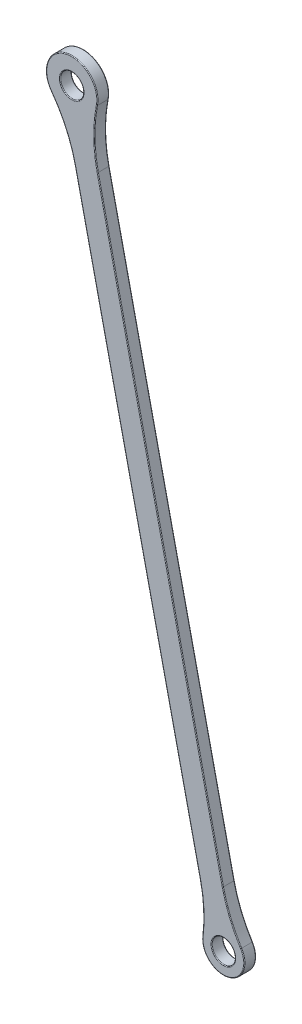
from build123d import *

# Parameters (mm, degrees)
BOSS_EXTRUDE1_DEPTH = 2.5
FILLET1_R           = 30
FILLET2_R           = 0.15


with BuildPart() as part:
    # Sketch1 → Boss-Extrude1 (new body)
    with BuildSketch(Plane.XY):
        with BuildLine():
            Line((12.060958277, 80.951296551), (-20.422285901, 225.342566543))
            ThreePointArc((-20.422285901, 225.342566543), (-17.434540729, 223.452228269), (-15.544202455, 226.439973441))
            Line((-15.544202455, 226.439973441), (16.939041723, 82.048703449))
            ThreePointArc((16.939041723, 82.048703449), (13.951296551, 83.939041723), (12.060958277, 80.951296551))
        make_face()
        with BuildLine():
            ThreePointArc((-14.468967679, 221.660447295), (-19.190391766, 231.257161782), (-19.347051125, 220.563040398))
            Line((-19.347051125, 220.563040398), (-20.422285901, 225.342566543))
            ThreePointArc((-20.422285901, 225.342566543), (-18.531947627, 228.330311715), (-15.544202455, 226.439973441))
            Line((-15.544202455, 226.439973441), (-14.468967679, 221.660447295))
        make_face()
        with BuildLine():
            ThreePointArc((16.939041723, 82.048703449), (15.048703449, 79.060958277), (12.060958277, 80.951296551))
            Line((12.060958277, 80.951296551), (11.239734152, 84.601719942))
            ThreePointArc((11.239734152, 84.601719942), (15.487666208, 77.109724899), (16.117817598, 85.69912684))
            Line((16.117817598, 85.69912684), (16.939041723, 82.048703449))
        make_face()
    extrude(amount=-BOSS_EXTRUDE1_DEPTH)

    # Fillet1
    fillet1_edges = [part.edges().sort_by_distance(p)[0] for p in [
        (-19.347051125, 220.563040398, -1.25),
        (-14.468967679, 221.660447295, -1.25),
        (16.117817598, 85.69912684, -1.25),
        (11.239734152, 84.601719942, -1.25),
    ]]
    fillet(fillet1_edges, radius=FILLET1_R)

    # Fillet2
    fillet2_edges = [part.edges().sort_by_distance(p)[0] for p in [
        (0.994489871, 152.923831522, 0),
        (0.994489871, 152.923831522, -2.5),
        (-19.190391766, 231.257161782, 0),
        (-19.190391766, 231.257161782, -2.5),
        (-17.434540729, 223.452228269, -2.5),
        (-3.883593575, 151.826424625, 0),
        (-3.883593575, 151.826424625, -2.5),
        (15.487666208, 77.109724899, 0),
        (15.487666208, 77.109724899, -2.5),
        (-13.137834588, 218.662323044, 0),
        (-13.137834588, 218.662323044, -2.5),
        (-19.265962453, 217.283697634, 0),
        (-19.265962453, 217.283697634, -2.5),
        (10.213987054, 87.165747363, 0),
        (15.048703449, 79.060958277, -2.5),
        (10.213987054, 87.165747363, -2.5),
        (15.946671133, 88.455411044, 0),
        (15.946671133, 88.455411044, -2.5),
        (15.048703449, 79.060958277, 0),
        (-17.434540729, 223.452228269, 0),
    ]]
    fillet(fillet2_edges, radius=FILLET2_R)


solid = part.part
